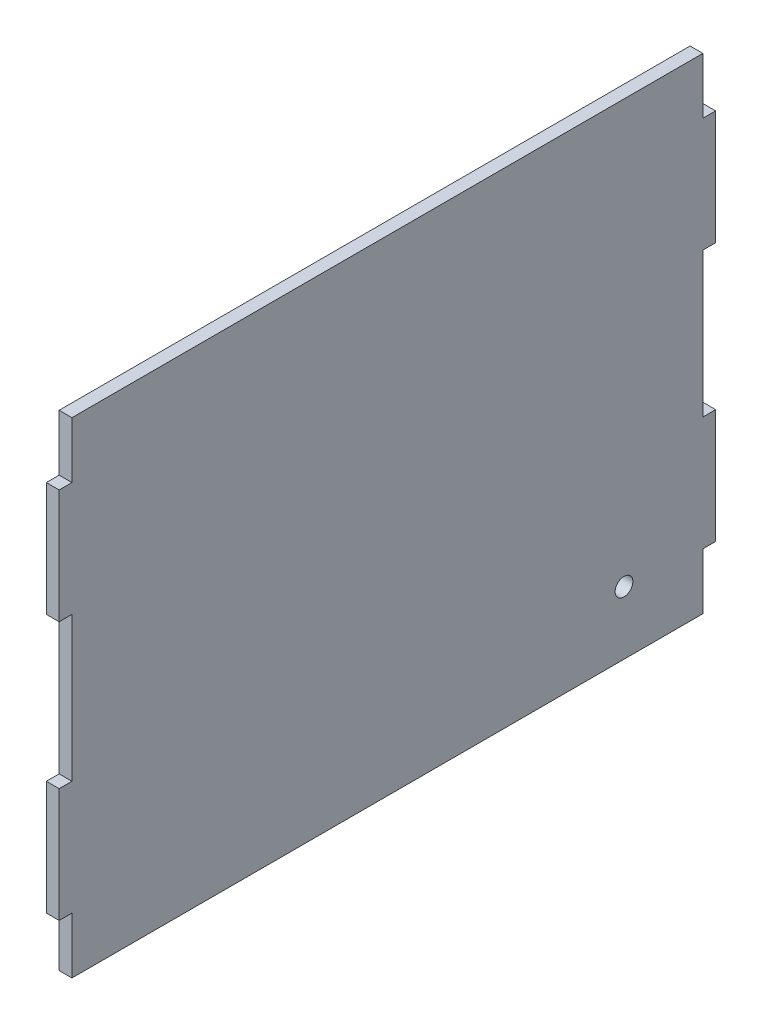
from build123d import *

# Parameters (mm, degrees)
BOSS_EXTRUDE1_DEPTH = 5.7
SKETCH2_R           = 3.95
CUT_EXTRUDE1_DEPTH  = 10


with BuildPart() as part:
    # Sketch1 → Boss-Extrude1 (new body)
    with BuildSketch(Plane(origin=(0, 0, 0), x_dir=(0, 0, -1), z_dir=(1, 0, 0))):
        Polygon((-140.35, 82.95), (-140.35, 107.95), (140.35, 107.95), (140.35, 82.95), (146.05, 82.95), (146.05, 32.15), (140.35, 32.15), (140.35, -32.15), (146.05, -32.15), (146.05, -82.95), (140.35, -82.95), (140.35, -107.95), (-140.35, -107.95), (-140.35, -82.95), (-146.05, -82.95), (-146.05, -32.15), (-140.35, -32.15), (-140.35, 32.15), (-146.05, 32.15), (-146.05, 82.95), align=None)
    extrude(amount=BOSS_EXTRUDE1_DEPTH)

    # Sketch2 → Cut-Extrude1 (cut)
    with BuildSketch(Plane(origin=(5.7, 0, 0), x_dir=(0, 0, -1), z_dir=(1, 0, 0))):
        with Locations((105.2625, -79.970674176)):
            Circle(SKETCH2_R)
    extrude(amount=-CUT_EXTRUDE1_DEPTH, mode=Mode.SUBTRACT)


solid = part.part
